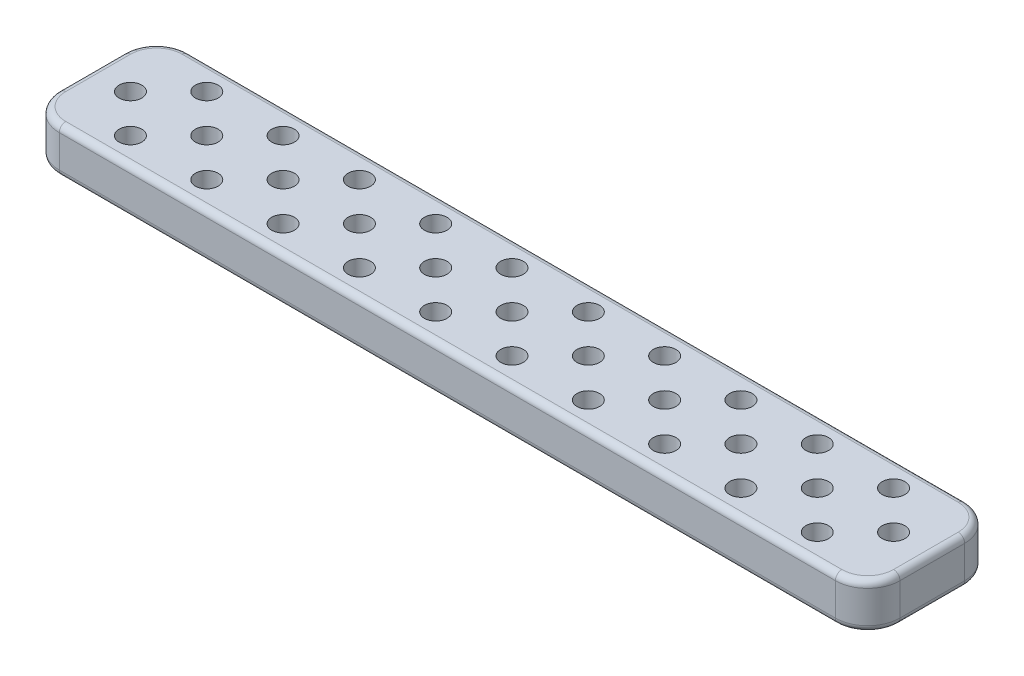
from build123d import *

# Parameters (mm, degrees)
SKETCH_1_W             = 164.510865215
SKETCH_1_H             = 20
EXTRUDE_2_DEPTH        = 7
SKETCH_1_3_R           = 1.75
CUT_EXTRUDE_1_DEPTH    = 165.963101249
SKETCH_1_4_R           = 1.75
CUT_EXTRUDE_2_DEPTH    = 4
PATTERN_LINEAR_1_COUNT = 10
PATTERN_LINEAR_1_PITCH = 11.8
SKETCH_1_6_R           = 1.75
CUT_EXTRUDE_4_DEPTH    = 165.963101249
SKETCH_1_7_R           = 1.75
CUT_EXTRUDE_5_DEPTH    = 4
CUT_EXTRUDE_14_DEPTH   = 165.963101249
FILLET_6_R             = 5
FILLET_5_R             = 1


with BuildPart() as part:
    # Эскиз1 → Бобышка-Вытянуть2 (new body)
    with BuildSketch(Plane(origin=(0, 0, 0), x_dir=(1, 0, 0), z_dir=(0, 1, 0))):
        with Locations((82.255432608, 0)):
            Rectangle(SKETCH_1_W, SKETCH_1_H)
    extrude(amount=EXTRUDE_2_DEPTH)

    # Эскиз1<3> → Вырез-Вытянуть1 (cut, through all)
    with BuildSketch(Plane(origin=(0, 0, 0), x_dir=(1, 0, 0), z_dir=(0, 1, 0))):
        with Locations((11.9, -5.9)):
            Circle(SKETCH_1_3_R)
        with Locations((11.9, 5.9)):
            Circle(SKETCH_1_3_R)
        with Locations((17.8, 0)):
            Circle(SKETCH_1_3_R)
    cut_extrude_1 = extrude(amount=CUT_EXTRUDE_1_DEPTH, mode=Mode.SUBTRACT)

    # Эскиз1<4> → Вырез-Вытянуть2 (cut)
    # profile 1 of 3: a face of its own
    with BuildSketch(Plane(origin=(0, 0, 0), x_dir=(1, 0, 0), z_dir=(0, 1, 0))):
        Polygon((15.364101615, -5.9), (13.632050808, -2.9), (10.167949192, -2.9), (8.435898385, -5.9), (10.167949192, -8.9), (13.632050808, -8.9), align=None)
        with Locations((11.9, -5.9)):
            Circle(SKETCH_1_4_R, mode=Mode.SUBTRACT)
    # profile 2 of 3: a face of its own
    with BuildSketch(Plane(origin=(0, 0, 0), x_dir=(1, 0, 0), z_dir=(0, 1, 0))):
        Polygon((8.435898385, 5.9), (10.167949192, 2.9), (13.632050808, 2.9), (15.364101615, 5.9), (13.632050808, 8.9), (10.167949192, 8.9), align=None)
        with Locations((11.9, 5.9)):
            Circle(SKETCH_1_4_R, mode=Mode.SUBTRACT)
    # profile 3 of 3: a face of its own
    with BuildSketch(Plane(origin=(0, 0, 0), x_dir=(1, 0, 0), z_dir=(0, 1, 0))):
        Polygon((17.8, 3.464101615), (14.8, 1.732050808), (14.8, -1.732050808), (17.8, -3.464101615), (20.8, -1.732050808), (20.8, 1.732050808), align=None)
        with Locations((17.8, 0)):
            Circle(SKETCH_1_4_R, mode=Mode.SUBTRACT)
    cut_extrude_2 = extrude(amount=CUT_EXTRUDE_2_DEPTH, mode=Mode.SUBTRACT)

    # Линейный массив1: Вырез-Вытянуть1, Вырез-Вытянуть2 ×10
    with Locations(*[(i * PATTERN_LINEAR_1_PITCH, 0, 0) for i in range(1, PATTERN_LINEAR_1_COUNT)]):
        add(cut_extrude_1, mode=Mode.SUBTRACT)
        add(cut_extrude_2, mode=Mode.SUBTRACT)

    # Эскиз1<6> → Вырез-Вытянуть4 (cut, through all)
    with BuildSketch(Plane(origin=(0, 0, 0), x_dir=(1, 0, 0), z_dir=(0, 1, 0))):
        with Locations((6, 0)):
            Circle(SKETCH_1_6_R)
    extrude(amount=CUT_EXTRUDE_4_DEPTH, mode=Mode.SUBTRACT)

    # Эскиз1<7> → Вырез-Вытянуть5 (cut)
    with BuildSketch(Plane(origin=(0, 0, 0), x_dir=(1, 0, 0), z_dir=(0, 1, 0))):
        Polygon((6, -3.464101615), (9, -1.732050808), (9, 1.732050808), (6, 3.464101615), (3, 1.732050808), (3, -1.732050808), align=None)
        with Locations((6, 0)):
            Circle(SKETCH_1_7_R, mode=Mode.SUBTRACT)
    extrude(amount=CUT_EXTRUDE_5_DEPTH, mode=Mode.SUBTRACT)

    # Эскиз6 → Вырез-Вытянуть14 (cut, through all)
    with BuildSketch(Plane.XZ):
        Polygon((130, 14.732791645), (130, -16.80364667), (181.887605339, -16.80364667), (181.887605339, 18.439642522), (130, 18.439642522), align=None)
    extrude(amount=-CUT_EXTRUDE_14_DEPTH, mode=Mode.SUBTRACT)

    # Скругление6
    fillet_6_edges = [part.edges().sort_by_distance(p)[0] for p in [
        (0, 3.5, -10),
        (0, 3.5, 10),
        (130, 3.5, -10),
        (130, 3.5, 10),
    ]]
    fillet(fillet_6_edges, radius=FILLET_6_R)

    # Скругление5
    fillet_5_edges = [part.edges().sort_by_distance(p)[0] for p in [
        (65, 7, 10),
        (0, 7, 0),
        (65, 7, -10),
        (65, 0, -10),
        (0, 0, 0),
        (65, 0, 10),
        (128.535533906, 7, -8.535533906),
        (130, 7, 0),
        (128.535533906, 7, 8.535533906),
        (1.464466094, 7, 8.535533906),
        (1.464466094, 7, -8.535533906),
        (128.535533906, 0, 8.535533906),
        (130, 0, 0),
        (128.535533906, 0, -8.535533906),
        (1.464466094, 0, -8.535533906),
        (1.464466094, 0, 8.535533906),
    ]]
    fillet(fillet_5_edges, radius=FILLET_5_R)


solid = part.part
